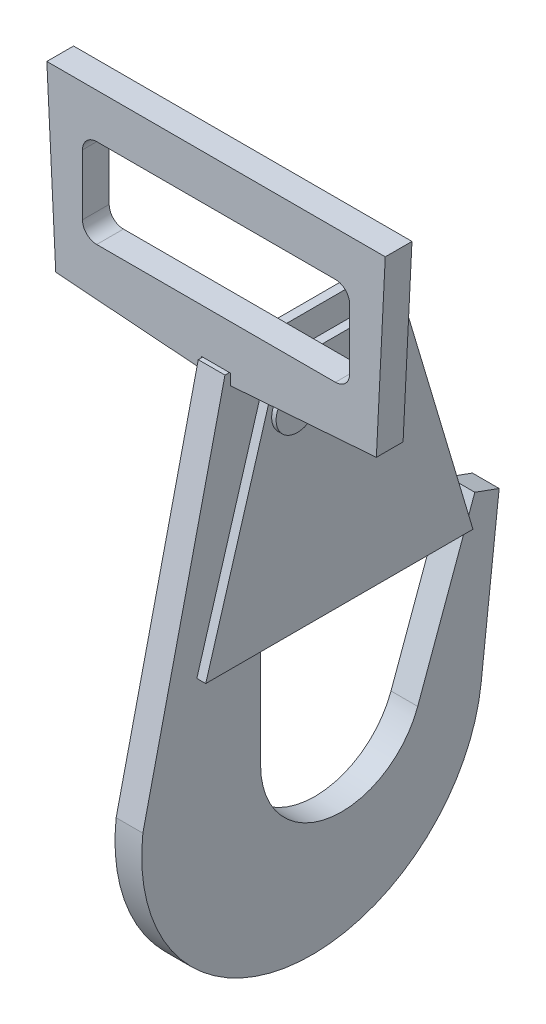
from build123d import *

# Parameters (mm, degrees)
SKETCH1_W           = 47.625
SKETCH1_H           = 15.875
BOSS_EXTRUDE1_DEPTH = 2.38125
BOSS_EXTRUDE2_DEPTH = 2.38125
BOSS_EXTRUDE3_DEPTH = 1.5875
SKETCH4_W           = 7.9375
SKETCH4_H           = 43.875429772
BOSS_EXTRUDE4_DEPTH = 1.5875
SKETCH5_W           = 8.89
SKETCH5_H           = 8.89
BOSS_EXTRUDE5_DEPTH = 2.38125
FILLET4_R           = 2.54
SKETCH6_R           = 3.81
BOSS_EXTRUDE6_DEPTH = 0.79375
BOSS_EXTRUDE7_DEPTH = 4.7625
FILLET5_R           = 2.54


with BuildPart() as part:
    # Sketch1 → Boss-Extrude1 (new body, symmetric)
    with BuildSketch(Plane.XY):
        Polygon((30.1625, 19.05), (-30.1625, 19.05), (-28.575, -12.7), (28.575, -12.7), align=None)
        with Locations((0, 3.175)):
            Rectangle(SKETCH1_W, SKETCH1_H, mode=Mode.SUBTRACT)
    extrude(amount=BOSS_EXTRUDE1_DEPTH, both=True)

    # Sketch2 → Boss-Extrude2 (add, symmetric)
    with BuildSketch(Plane(origin=(0, 0, 0), x_dir=(0, 0, -1), z_dir=(1, 0, 0))):
        with BuildLine():
            Line((-3.175, -12.7), (-17.80991483, -76.090780508))
            ThreePointArc((-17.80991483, -76.090780508), (8.869373473, -109.769781966), (42.495651539, -83.024072273))
            Line((42.495651539, -83.024072273), (45.702036783, -54.641440894))
            Line((45.702036783, -54.641440894), (41.366666318, -53.06349509))
            Line((41.366666318, -53.06349509), (31.187631555, -81.030163252))
            ThreePointArc((31.187631555, -81.030163252), (15.108998658, -90.313166283), (3.175, -76.090780508))
            Line((3.175, -76.090780508), (3.175, -12.7))
            Line((3.175, -12.7), (-3.175, -12.7))
        make_face()
    extrude(amount=BOSS_EXTRUDE2_DEPTH, both=True)

    # Sketch5 → Boss-Extrude5 (add, symmetric)
    with BuildSketch(Plane(origin=(0, 0, 0), x_dir=(0, 0, -1), z_dir=(1, 0, 0))):
        with Locations((7.62, -22.225)):
            Rectangle(SKETCH5_W, SKETCH5_H)
    extrude(amount=BOSS_EXTRUDE5_DEPTH, both=True)

    # Fillet4
    fillet4_edges = [part.edges().sort_by_distance(p)[0] for p in [
        (0, -17.78, -3.175),
        (0, -26.67, -3.175),
        (0, -26.67, -12.065),
        (0, -17.78, -12.065),
    ]]
    fillet(fillet4_edges, radius=FILLET4_R)


with BuildPart() as body_2:
    # Sketch3 → Boss-Extrude3 (new body)
    with BuildSketch(Plane(origin=(2.38125, 0, 0), x_dir=(0, 0, -1), z_dir=(1, 0, 0))):
        Polygon((37.855386763, -57.019232038), (-8.190255907, -57.019232038), (4.349041665, -14.973788123), (25.316089191, -14.973788123), align=None)
    extrude(amount=BOSS_EXTRUDE3_DEPTH)


with BuildPart() as body_3:
    # Mirror1: mirrored copy
    add(body_2.part.mirror(Plane(origin=(0, 0, 0), x_dir=(0, 0, 1), z_dir=(1, 0, 0))))


with BuildPart() as body_2_1:
    add(body_2.part)

    add(body_3.part)  # Boss-Extrude4 merges body 3
    # Sketch4 → Boss-Extrude4 (add, along a direction that is not the sketch's normal)
    with BuildSketch(Plane(origin=(0, 5.710370927, -19.147410704), x_dir=(-1, 0, 0), z_dir=(0, 0.285793157, -0.958291329))):
        with Locations((0, -43.522131252)):
            Rectangle(SKETCH4_W, SKETCH4_H)
    extrude(amount=BOSS_EXTRUDE4_DEPTH, dir=(0, 0, -1))


with BuildPart() as body_3_2:
    # Sketch6 → Boss-Extrude6 (new body)
    with BuildSketch(Plane(origin=(3.96875, 0, 0), x_dir=(0, 0, -1), z_dir=(1, 0, 0))):
        with Locations((7.3700929, -21.831498009)):
            Circle(SKETCH6_R)
    extrude(amount=BOSS_EXTRUDE6_DEPTH)


with BuildPart() as body_4:
    # Mirror2: mirrored copy
    add(body_3_2.part.mirror(Plane(origin=(0, 0, 0), x_dir=(0, 0, 1), z_dir=(1, 0, 0))))


with BuildPart() as body_5:
    # Sketch7 → Boss-Extrude7 (new body)
    with BuildSketch(Plane(origin=(0, 0, -2.38125), x_dir=(-1, 0, 0), z_dir=(0, 0, -1))):
        Polygon((-28.575, -12.7), (-2.588815181, -14.646611678), (-2.588815181, -12.7), align=None)
    extrude(amount=-BOSS_EXTRUDE7_DEPTH)


with BuildPart() as body_6:
    # Mirror3: mirrored copy
    add(body_5.part.mirror(Plane(origin=(0, 0, 0), x_dir=(0, 0, 1), z_dir=(1, 0, 0))))


with BuildPart() as body_5_1:
    add(body_5.part)

    # Combine1: union part, body 6
    add(part.part)
    add(body_6.part)

    # Fillet5
    fillet5_edges = [body_5_1.edges().sort_by_distance(p)[0] for p in [
        (-23.8125, -4.7625, 0),
        (23.8125, -4.7625, 0),
        (23.8125, 11.1125, 0),
        (-23.8125, 11.1125, 0),
    ]]
    fillet(fillet5_edges, radius=FILLET5_R)


solid = Compound([body_2_1.part, body_3_2.part, body_4.part, body_5_1.part])
